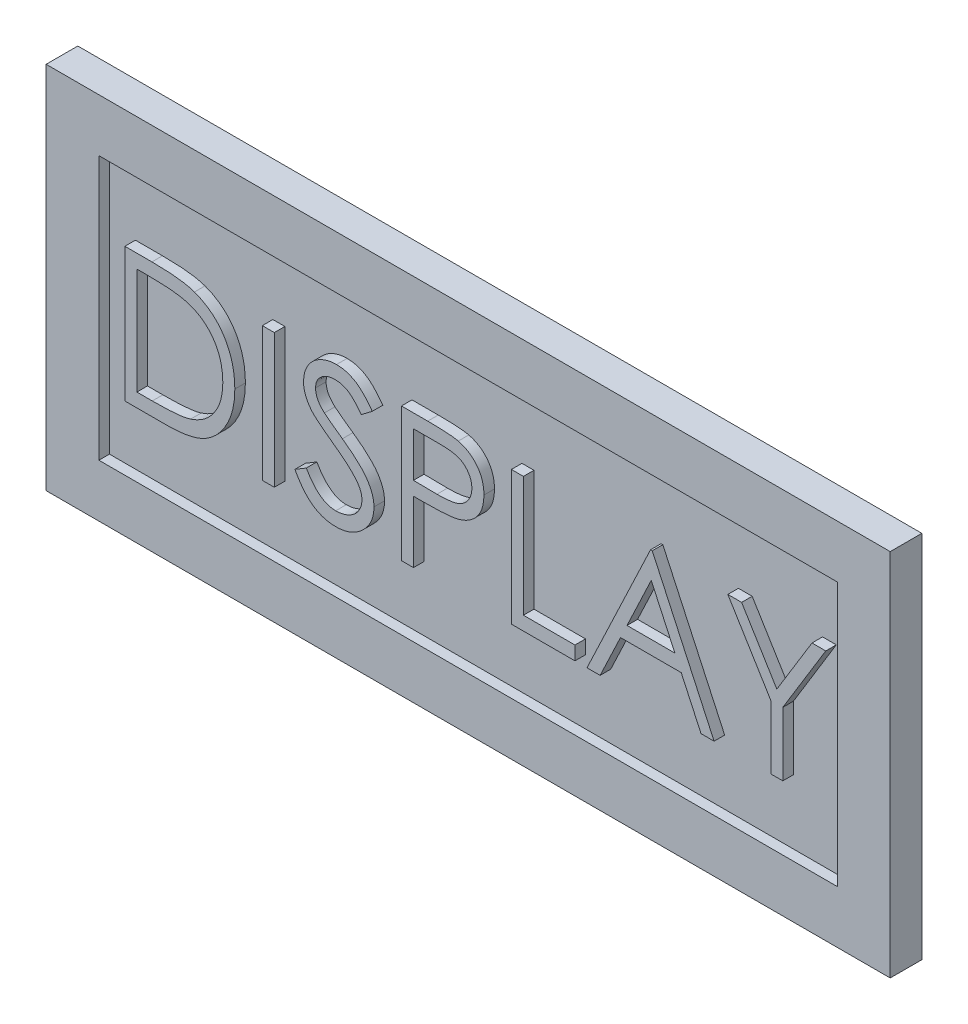
from build123d import *

# Parameters (mm, degrees)
SKETCH_1_W          = 80
SKETCH_1_H          = 35
EXTRUDE_1_DEPTH     = 3
SKETCH_1_4_W        = 70
SKETCH_1_4_H        = 25
CUT_EXTRUDE_1_DEPTH = 4
SKETCH_1_5_W        = 70
SKETCH_1_5_H        = 25
EXTRUDE_2_DEPTH     = 2
SKETCH_8_W          = 1.139743589
SKETCH_8_H          = 12.7
EXTRUDE_3_DEPTH     = 1


with BuildPart() as part:
    # 스케치1 → 보스-돌출1 (new body)
    with BuildSketch(Plane.XY):
        with Locations((40, -17.5)):
            Rectangle(SKETCH_1_W, SKETCH_1_H)
    extrude(amount=EXTRUDE_1_DEPTH)

    # 스케치1<4> → 컷-돌출1 (cut, through all)
    with BuildSketch(Plane.XY):
        with Locations((40, -17.5)):
            Rectangle(SKETCH_1_4_W, SKETCH_1_4_H)
    extrude(amount=CUT_EXTRUDE_1_DEPTH, mode=Mode.SUBTRACT)

    # 스케치1<5> → 보스-돌출2 (add)
    with BuildSketch(Plane.XY):
        with Locations((40, -17.5)):
            Rectangle(SKETCH_1_5_W, SKETCH_1_5_H)
    extrude(amount=EXTRUDE_2_DEPTH)

    # 스케치8 → 보스-돌출3 (add)
    with BuildSketch(Plane.XY.offset(2)):
        with BuildLine():
            Line((7.462006088, -23.907402716), (7.462006088, -11.207402716))
            Line((7.462006088, -11.207402716), (10.026429165, -11.207402716))
            add(Edge.make_bspline(
                [(10.026429165, -11.207402716), (10.249473779, -11.209008613), (10.680394813, -11.212111197), (11.303102837, -11.231783102), (11.879261061, -11.266582792), (12.406974578, -11.317272216), (12.887692119, -11.379513224), (13.32006764, -11.457528976), (13.706336844, -11.549651766), (13.943897385, -11.628193828), (14.056236857, -11.665335408)],
                knots=[0, 0, 0, 0, 0.000669134, 0.001292764, 0.001868826, 0.002400433, 0.002882928, 0.003322552, 0.003718071, 0.004072903, 0.004072903, 0.004072903, 0.004072903], degree=3))
            add(Edge.make_bspline(
                [(14.056236857, -11.665335408), (14.203174911, -11.721326826), (14.493718952, -11.832039961), (14.90740194, -12.040887112), (15.296839685, -12.27751751), (15.664120582, -12.542243069), (16.00085501, -12.842559419), (16.320197949, -13.165709415), (16.609085661, -13.52344425), (16.873638621, -13.908344921), (17.112165157, -14.315877224), (17.319498672, -14.745264619), (17.491688877, -15.194326488), (17.634630013, -15.661814025), (17.747284302, -16.148755167), (17.824144454, -16.65571691), (17.874839189, -17.180695683), (17.879933889, -17.536928737), (17.882518909, -17.717679158)],
                knots=[0, 0, 0, 0, 0.000471477, 0.000932263, 0.001387773, 0.001837613, 0.002288266, 0.002739829, 0.003199145, 0.003665599, 0.004139895, 0.004614383, 0.005094398, 0.005581273, 0.006079917, 0.006592294, 0.007118596, 0.007660698, 0.007660698, 0.007660698, 0.007660698], degree=3))
            add(Edge.make_bspline(
                [(17.882518909, -17.717679158), (17.880236655, -17.874655652), (17.875739236, -18.183994229), (17.835355719, -18.639891193), (17.776658786, -19.082263295), (17.685784125, -19.509003978), (17.575466434, -19.923852083), (17.434082228, -20.322386227), (17.272119142, -20.708262335), (17.083252439, -21.07626289), (16.875910842, -21.42490827), (16.653400517, -21.753568043), (16.415958794, -22.05755242), (16.161321497, -22.337781955), (15.892779212, -22.593834196), (15.608573784, -22.827848081), (15.307971857, -23.035244722), (14.992319805, -23.224173944), (14.652409279, -23.388984948), (14.281801994, -23.528430984), (13.878917433, -23.643988702), (13.444744504, -23.740403096), (12.978533028, -23.816883594), (12.479825923, -23.868142218), (11.949389415, -23.902805716), (11.585156081, -23.905840629), (11.397683171, -23.907402716)],
                knots=[0, 0, 0, 0, 0.000470825, 0.00092781, 0.001372149, 0.001808729, 0.0022358, 0.002659019, 0.003076254, 0.003490407, 0.003898792, 0.004292531, 0.004680333, 0.005054942, 0.00542743, 0.00579259, 0.006158158, 0.00652204, 0.006895248, 0.007289784, 0.007708436, 0.008151601, 0.00862338, 0.009124872, 0.009655071, 0.010217403, 0.010217403, 0.010217403, 0.010217403], degree=3))
            Line((11.397683171, -23.907402716), (7.462006088, -23.907402716))
        make_face()
        with BuildLine():
            Line((8.601749678, -22.604838613), (10.059502082, -22.604838613))
            add(Edge.make_bspline(
                [(10.059502082, -22.604838613), (10.268973598, -22.603938378), (10.671864038, -22.602206896), (11.251194486, -22.58701333), (11.780528296, -22.562186871), (12.25994063, -22.527443017), (12.689160804, -22.481474042), (13.069085839, -22.430220824), (13.398470348, -22.366367216), (13.597785733, -22.308488021), (13.689890703, -22.281741658)],
                knots=[0, 0, 0, 0, 0.000628406, 0.001208655, 0.001738433, 0.002218042, 0.002650422, 0.003033235, 0.00336802, 0.003655635, 0.003655635, 0.003655635, 0.003655635], degree=3))
            add(Edge.make_bspline(
                [(13.689890703, -22.281741658), (13.805817617, -22.240914575), (14.034902533, -22.160235564), (14.364671042, -22.013069193), (14.672217888, -21.838745112), (14.962902837, -21.644971146), (15.232602415, -21.424912796), (15.48451278, -21.183355208), (15.718126745, -20.919069024), (15.931030662, -20.632382266), (16.121560794, -20.325079294), (16.286556398, -20.00018124), (16.431160527, -19.661247957), (16.544657134, -19.303074724), (16.633613683, -18.92886357), (16.696622693, -18.538588167), (16.735864693, -18.132321402), (16.740441947, -17.855997979), (16.742775319, -17.715135088)],
                knots=[0, 0, 0, 0, 0.000368636, 0.000728467, 0.00108158, 0.001428031, 0.001775294, 0.002124361, 0.00247402, 0.002832229, 0.003194399, 0.003557355, 0.003924487, 0.004298604, 0.004683036, 0.005077441, 0.005483744, 0.005906251, 0.005906251, 0.005906251, 0.005906251], degree=3))
            add(Edge.make_bspline(
                [(16.742775319, -17.715135088), (16.740912819, -17.566605031), (16.737253922, -17.274816419), (16.691264281, -16.846678753), (16.624057494, -16.434906107), (16.526870976, -16.039470941), (16.403024644, -15.659601777), (16.248466944, -15.297399554), (16.07187664, -14.94903903), (15.861770246, -14.622560617), (15.631662236, -14.313794193), (15.376291074, -14.030929213), (15.099713962, -13.773321324), (14.804947509, -13.536958675), (14.48368432, -13.33135048), (14.143492356, -13.147430237), (13.779380921, -12.991344003), (13.526060567, -12.908326415), (13.397322594, -12.86613669)],
                knots=[0, 0, 0, 0, 0.000445394, 0.00087498, 0.001290296, 0.001696304, 0.002095342, 0.002487525, 0.00287666, 0.003265537, 0.003650709, 0.004030799, 0.004406986, 0.004783646, 0.005162584, 0.005549584, 0.005942765, 0.00634906, 0.00634906, 0.00634906, 0.00634906], degree=3))
            add(Edge.make_bspline(
                [(13.397322594, -12.86613669), (13.290819863, -12.836685652), (13.064365836, -12.774064664), (12.694834066, -12.705755455), (12.27894481, -12.645504845), (11.814851609, -12.594494245), (11.303083486, -12.557891679), (10.743246846, -12.530418623), (10.13509971, -12.511888842), (9.713523087, -12.510623533), (9.494718428, -12.509966818)],
                knots=[0, 0, 0, 0, 0.000331365, 0.000704572, 0.001126244, 0.001592052, 0.002104832, 0.002665226, 0.00327352, 0.00392991, 0.00392991, 0.00392991, 0.00392991], degree=3))
            Line((9.494718428, -12.509966818), (8.601749678, -12.509966818))
            Line((8.601749678, -12.509966818), (8.601749678, -22.604838613))
        make_face(mode=Mode.SUBTRACT)
        with Locations((21.057518909, -17.557402716)):
            Rectangle(SKETCH_8_W, SKETCH_8_H)
        with BuildLine():
            Line((23.581236857, -21.457462812), (24.654834614, -20.813812972))
            add(Edge.make_bspline(
                [(24.654834614, -20.813812972), (24.754686503, -20.980960883), (24.94599887, -21.301209831), (25.265136659, -21.733946149), (25.595818937, -22.101745975), (25.940494518, -22.402469665), (26.29705953, -22.639229911), (26.667841668, -22.806878009), (27.051591438, -22.911438834), (27.31275359, -22.924139148), (27.443135896, -22.930479639)],
                knots=[0, 0, 0, 0, 0.000583841, 0.001118616, 0.00161028, 0.002064766, 0.002487434, 0.002889373, 0.003281209, 0.003671854, 0.003671854, 0.003671854, 0.003671854], degree=3))
            add(Edge.make_bspline(
                [(27.443135896, -22.930479639), (27.554485361, -22.927378399), (27.775235938, -22.921230183), (28.100218933, -22.862154129), (28.415838616, -22.771395833), (28.715589959, -22.641417025), (28.995336903, -22.484160233), (29.240652626, -22.294218389), (29.452728522, -22.081561586), (29.626207309, -21.844315953), (29.759303437, -21.589165157), (29.861600371, -21.327269562), (29.918369639, -21.054515043), (29.926921287, -20.870871363), (29.931236857, -20.778195985)],
                knots=[0, 0, 0, 0, 0.000333749, 0.000661658, 0.000987706, 0.001317082, 0.001639577, 0.001947946, 0.002244774, 0.002537873, 0.002825803, 0.003105997, 0.003378925, 0.003656975, 0.003656975, 0.003656975, 0.003656975], degree=3))
            add(Edge.make_bspline(
                [(29.931236857, -20.778195985), (29.925887216, -20.67245633), (29.915012176, -20.457503064), (29.823095091, -20.140367181), (29.678499252, -19.826522712), (29.545103374, -19.632389549), (29.475848236, -19.531601434)],
                knots=[0, 0, 0, 0, 0.000316704, 0.000643812, 0.000983014, 0.001349263, 0.001349263, 0.001349263, 0.001349263], degree=3))
            add(Edge.make_bspline(
                [(29.475848236, -19.531601434), (29.418986293, -19.458860102), (29.299611756, -19.306148776), (29.094388782, -19.078836065), (28.853574596, -18.844363516), (28.585410268, -18.593777795), (28.280127346, -18.338733504), (27.947287508, -18.06706861), (27.578392934, -17.789114316), (27.319677617, -17.602705292), (27.186184774, -17.506521306)],
                knots=[0, 0, 0, 0, 0.00027693, 0.00058138, 0.000917785, 0.001285048, 0.001682135, 0.002110847, 0.002573875, 0.003067483, 0.003067483, 0.003067483, 0.003067483], degree=3))
            add(Edge.make_bspline(
                [(27.186184774, -17.506521306), (27.052566274, -17.411349002), (26.797097876, -17.229386805), (26.439833877, -16.959332974), (26.120358254, -16.712430933), (25.840090965, -16.486356375), (25.599155285, -16.281078638), (25.395652623, -16.098568973), (25.234767001, -15.933891481), (25.145302466, -15.827061469), (25.105135094, -15.779097427)],
                knots=[0, 0, 0, 0, 0.000492118, 0.000940893, 0.001343419, 0.001703394, 0.002021005, 0.002292935, 0.002523226, 0.002710868, 0.002710868, 0.002710868, 0.002710868], degree=3))
            add(Edge.make_bspline(
                [(25.105135094, -15.779097427), (25.048991859, -15.704345094), (24.938578651, -15.557334597), (24.792833432, -15.327555828), (24.668957041, -15.092339979), (24.571848007, -14.851054985), (24.490073727, -14.607088243), (24.435072093, -14.35725658), (24.400631881, -14.102681021), (24.397104959, -13.931363462), (24.395339421, -13.845603838)],
                knots=[0, 0, 0, 0, 0.000280379, 0.000551403, 0.000815399, 0.001076659, 0.001330888, 0.001586412, 0.00184296, 0.002100112, 0.002100112, 0.002100112, 0.002100112], degree=3))
            add(Edge.make_bspline(
                [(24.395339421, -13.845603838), (24.400075465, -13.711238656), (24.409446324, -13.445380253), (24.488696201, -13.05701124), (24.613783558, -12.686220526), (24.789025008, -12.336679029), (25.01493026, -12.017488184), (25.276354224, -11.724976389), (25.587727331, -11.479073247), (25.92936685, -11.264218064), (26.303314257, -11.096048564), (26.695166964, -10.96919015), (27.105547768, -10.897310844), (27.383507714, -10.886995668), (27.524546152, -10.88176169)],
                knots=[0, 0, 0, 0, 0.000402767, 0.000796926, 0.001183901, 0.001574148, 0.001965141, 0.002354126, 0.002746681, 0.003151188, 0.003562179, 0.00397332, 0.004384052, 0.004807133, 0.004807133, 0.004807133, 0.004807133], degree=3))
            add(Edge.make_bspline(
                [(27.524546152, -10.88176169), (27.674203316, -10.88692352), (27.97182365, -10.897188753), (28.409607946, -10.986442652), (28.831105403, -11.134127947), (29.170170964, -11.301726792), (29.435538412, -11.469117929), (29.637913757, -11.621589863), (29.842991364, -11.797122399), (30.052425449, -11.996183092), (30.26266727, -12.220598446), (30.476838082, -12.468831518), (30.695438715, -12.739365306), (30.836067122, -12.932494209), (30.908159934, -13.031501274)],
                knots=[0, 0, 0, 0, 0.00044863, 0.000892182, 0.001333892, 0.001785577, 0.002023431, 0.002274276, 0.002544978, 0.002832897, 0.003140645, 0.00346709, 0.003816333, 0.004183702, 0.004183702, 0.004183702, 0.004183702], degree=3))
            Line((30.908159934, -13.031501274), (29.877811377, -13.812530921))
            add(Edge.make_bspline(
                [(29.877811377, -13.812530921), (29.815596136, -13.73238053), (29.695784129, -13.578029617), (29.513885705, -13.361870843), (29.342440611, -13.16441676), (29.17352916, -12.992911867), (29.016072269, -12.837964126), (28.863247573, -12.705304437), (28.717254356, -12.593632991), (28.533224423, -12.474457788), (28.302020131, -12.356324189), (28.011790528, -12.256360391), (27.708491758, -12.196289167), (27.501918524, -12.188346632), (27.397342627, -12.184325793)],
                knots=[0, 0, 0, 0, 0.000304354, 0.000586115, 0.000847462, 0.001088545, 0.001308044, 0.001510038, 0.001695249, 0.001858961, 0.002167298, 0.002471418, 0.002777268, 0.00309085, 0.00309085, 0.00309085, 0.00309085], degree=3))
            add(Edge.make_bspline(
                [(27.397342627, -12.184325793), (27.266146102, -12.188722533), (27.013145965, -12.197201231), (26.653952822, -12.289802321), (26.330669151, -12.435605071), (26.052892701, -12.639947991), (25.821618527, -12.882049879), (25.654321577, -13.160647439), (25.553628122, -13.468286443), (25.541340765, -13.682886167), (25.535083011, -13.792178357)],
                knots=[0, 0, 0, 0, 0.000392785, 0.000757449, 0.001104647, 0.001450678, 0.001785453, 0.002102647, 0.002418029, 0.002745345, 0.002745345, 0.002745345, 0.002745345], degree=3))
            add(Edge.make_bspline(
                [(25.535083011, -13.792178357), (25.536509499, -13.860219436), (25.539364808, -13.996412855), (25.579187645, -14.197622301), (25.630348068, -14.398323447), (25.711419903, -14.597613961), (25.82334429, -14.798979207), (25.970320214, -15.005886655), (26.155425661, -15.220159998), (26.297219391, -15.359523897), (26.37208221, -15.433103838)],
                knots=[0, 0, 0, 0, 0.00020378, 0.000407893, 0.000613397, 0.00082457, 0.001051163, 0.001303142, 0.001584604, 0.001899422, 0.001899422, 0.001899422, 0.001899422], degree=3))
            add(Edge.make_bspline(
                [(26.37208221, -15.433103838), (26.399882047, -15.457912474), (26.465928096, -15.516852116), (26.58667217, -15.613344106), (26.746121752, -15.732371308), (26.940113167, -15.879645285), (27.172223309, -16.050483733), (27.442477698, -16.242702269), (27.747863831, -16.462540934), (27.964569069, -16.616238296), (28.079153524, -16.697506883)],
                knots=[0, 0, 0, 0, 0.000111766, 0.000265529, 0.000463461, 0.000708709, 0.000996201, 0.001328024, 0.001703617, 0.002125051, 0.002125051, 0.002125051, 0.002125051], degree=3))
            add(Edge.make_bspline(
                [(28.079153524, -16.697506883), (28.216988124, -16.79780553), (28.483885723, -16.99201996), (28.863643227, -17.283813999), (29.207972188, -17.569193045), (29.518081526, -17.846334648), (29.79703488, -18.113136585), (30.041737466, -18.372808697), (30.254682649, -18.623490632), (30.483932956, -18.944882549), (30.718185616, -19.339602484), (30.919359085, -19.823212092), (31.046207946, -20.308701598), (31.062796016, -20.635007547), (31.070980447, -20.796004479)],
                knots=[0, 0, 0, 0, 0.000511383, 0.000990223, 0.001436481, 0.001852691, 0.002237729, 0.002594081, 0.002922749, 0.00322352, 0.00377766, 0.004295477, 0.004790951, 0.0052735, 0.0052735, 0.0052735, 0.0052735], degree=3))
            add(Edge.make_bspline(
                [(31.070980447, -20.796004479), (31.068595974, -20.909863118), (31.063873334, -21.135369338), (31.00958659, -21.466494903), (30.930049519, -21.788098344), (30.810171556, -22.096204381), (30.663856096, -22.396449663), (30.478195711, -22.68095833), (30.26299354, -22.956027262), (30.016128165, -23.214321645), (29.745995891, -23.451434984), (29.460486484, -23.662360436), (29.159132637, -23.838231209), (28.843569145, -23.981744265), (28.513723523, -24.093988743), (28.169706708, -24.175315439), (27.810951624, -24.225229019), (27.567109877, -24.230409753), (27.443135896, -24.233043742)],
                knots=[0, 0, 0, 0, 0.000341247, 0.000675867, 0.001004131, 0.001333458, 0.001665681, 0.002004415, 0.002350493, 0.00271219, 0.00307453, 0.00342767, 0.003775427, 0.004119254, 0.004466004, 0.00481897, 0.005178405, 0.005550153, 0.005550153, 0.005550153, 0.005550153], degree=3))
            add(Edge.make_bspline(
                [(27.443135896, -24.233043742), (27.347213366, -24.231188883), (27.15657635, -24.227502525), (26.874601945, -24.194913307), (26.598324007, -24.148804674), (26.331209326, -24.07560162), (26.069816433, -23.986785161), (25.815282182, -23.877426068), (25.567483215, -23.746372223), (25.325030843, -23.596530276), (25.088541695, -23.422149318), (24.860233911, -23.219045488), (24.632616581, -22.99282037), (24.412408029, -22.737330611), (24.195154048, -22.456703853), (23.985138105, -22.148314531), (23.778013015, -21.813842418), (23.648054032, -21.578474822), (23.581236857, -21.457462812)],
                knots=[0, 0, 0, 0, 0.00028766, 0.000571697, 0.000850676, 0.001127139, 0.001401486, 0.001678416, 0.001957221, 0.002241725, 0.002532773, 0.002837436, 0.003157645, 0.003494857, 0.003848519, 0.004221814, 0.00461365, 0.005028294, 0.005028294, 0.005028294, 0.005028294], degree=3))
        make_face()
        with BuildLine():
            Line((33.676108652, -11.207402716), (36.166753684, -11.207402716))
            add(Edge.make_bspline(
                [(36.166753684, -11.207402716), (36.338061829, -11.207591025), (36.666295843, -11.207951834), (37.136976188, -11.218891055), (37.564457215, -11.233502194), (37.947817168, -11.253756493), (38.288235581, -11.277692691), (38.584172068, -11.311264377), (38.837952744, -11.34631745), (38.990013289, -11.381955125), (39.059361857, -11.398208004)],
                knots=[0, 0, 0, 0, 0.000513909, 0.000984672, 0.001412348, 0.001797041, 0.002136358, 0.002435846, 0.002690583, 0.002904164, 0.002904164, 0.002904164, 0.002904164], degree=3))
            add(Edge.make_bspline(
                [(39.059361857, -11.398208004), (39.147149823, -11.422236222), (39.32065714, -11.469726463), (39.570669496, -11.564844831), (39.808536307, -11.677628688), (40.035073676, -11.806166984), (40.247497806, -11.955974603), (40.448978012, -12.120978873), (40.637736226, -12.304989421), (40.812710991, -12.505942392), (40.973401543, -12.720464296), (41.11175782, -12.95175753), (41.227608044, -13.195928831), (41.3269702, -13.452808361), (41.398483735, -13.724553249), (41.452356771, -14.00927532), (41.486551077, -14.306944053), (41.489826087, -14.510361286), (41.491493268, -14.613913133)],
                knots=[0, 0, 0, 0, 0.000272928, 0.000539425, 0.000801167, 0.00106213, 0.001319735, 0.001580002, 0.001842671, 0.002109519, 0.002378686, 0.002645705, 0.002916526, 0.003188682, 0.003470718, 0.003758119, 0.004057607, 0.004368151, 0.004368151, 0.004368151, 0.004368151], degree=3))
            add(Edge.make_bspline(
                [(41.491493268, -14.613913133), (41.489964098, -14.718335351), (41.486972174, -14.922644475), (41.451062796, -15.22154002), (41.402693243, -15.507175322), (41.328318225, -15.778917042), (41.230906783, -16.035151409), (41.116635619, -16.279794165), (40.978809666, -16.50868326), (40.820441284, -16.722649658), (40.644268356, -16.921894197), (40.451036266, -17.104973023), (40.241525119, -17.27081448), (40.016400753, -17.419790355), (39.773468445, -17.548445998), (39.51641263, -17.663679647), (39.242998988, -17.760457496), (39.053796151, -17.811366576), (38.957599037, -17.837250472)],
                knots=[0, 0, 0, 0, 0.000313086, 0.000612574, 0.000902017, 0.001181599, 0.001456135, 0.001723565, 0.001990583, 0.002256192, 0.00252113, 0.002787469, 0.003053674, 0.003321805, 0.003596116, 0.003877417, 0.00416629, 0.004465075, 0.004465075, 0.004465075, 0.004465075], degree=3))
            add(Edge.make_bspline(
                [(38.957599037, -17.837250472), (38.878034139, -17.854170432), (38.70366304, -17.891251508), (38.416488019, -17.932647909), (38.082131905, -17.967981488), (37.70105106, -17.994474188), (37.273587548, -18.017154096), (36.799510129, -18.03518118), (36.277888192, -18.045086649), (35.91404682, -18.045597526), (35.724085415, -18.045864254)],
                knots=[0, 0, 0, 0, 0.000243979, 0.000534694, 0.000869865, 0.0012525, 0.001680517, 0.002154049, 0.002675683, 0.00324556, 0.00324556, 0.00324556, 0.00324556], degree=3))
            Line((35.724085415, -18.045864254), (34.815852242, -18.045864254))
            Line((34.815852242, -18.045864254), (34.815852242, -23.907402716))
            Line((34.815852242, -23.907402716), (33.676108652, -23.907402716))
            Line((33.676108652, -23.907402716), (33.676108652, -11.207402716))
        make_face()
        with BuildLine():
            Line((34.815852242, -12.509966818), (34.815852242, -16.743300152))
            Line((34.815852242, -16.743300152), (37.03936987, -16.771284927))
            add(Edge.make_bspline(
                [(37.03936987, -16.771284927), (37.147936458, -16.771341038), (37.357522018, -16.771449359), (37.660276314, -16.756988691), (37.941161442, -16.740295329), (38.199314615, -16.71585355), (38.434852206, -16.681304987), (38.648166954, -16.64642811), (38.837604809, -16.595971508), (39.059307627, -16.528033514), (39.306352916, -16.412163738), (39.575112306, -16.243979851), (39.802879863, -16.029601281), (39.999977682, -15.78856315), (40.156390439, -15.520414881), (40.270893612, -15.233507596), (40.338171525, -14.930783685), (40.347192857, -14.723635295), (40.351749678, -14.619001274)],
                knots=[0, 0, 0, 0, 0.000325651, 0.000628662, 0.000909076, 0.001169816, 0.001406195, 0.001623278, 0.001817645, 0.001993849, 0.002318305, 0.00263304, 0.002940915, 0.003252021, 0.003564434, 0.003868203, 0.004175604, 0.004489361, 0.004489361, 0.004489361, 0.004489361], degree=3))
            add(Edge.make_bspline(
                [(40.351749678, -14.619001274), (40.347168075, -14.516898668), (40.338060415, -14.313931324), (40.270366283, -14.016465535), (40.156613058, -13.732581694), (39.998927701, -13.467793641), (39.807552744, -13.227622838), (39.585123699, -13.018990406), (39.332164151, -12.851271656), (39.096857712, -12.743019462), (38.887847694, -12.676924034), (38.706303154, -12.63067847), (38.501322707, -12.593755556), (38.272839621, -12.563857932), (38.022624824, -12.538263944), (37.748528653, -12.520897684), (37.451589433, -12.5107324), (37.245448219, -12.510228191), (37.13858862, -12.509966818)],
                knots=[0, 0, 0, 0, 0.000306146, 0.00060858, 0.000909985, 0.001220206, 0.001529716, 0.001828533, 0.002131234, 0.002436321, 0.002602057, 0.002788401, 0.002997974, 0.003226445, 0.00347959, 0.003752387, 0.004050218, 0.004370781, 0.004370781, 0.004370781, 0.004370781], degree=3))
            Line((37.13858862, -12.509966818), (34.815852242, -12.509966818))
        make_face(mode=Mode.SUBTRACT)
        Polygon((44.096621473, -11.207402716), (45.236365062, -11.207402716), (45.236365062, -22.604838613), (50.120980447, -22.604838613), (50.120980447, -23.907402716), (44.096621473, -23.907402716), align=None)
        Polygon((57.447903524, -11.207402716), (63.309441986, -23.907402716), (62.070479646, -23.907402716), (60.192955607, -19.836889895), (54.435724037, -19.836889895), (52.504774518, -23.907402716), (51.260724037, -23.907402716), (57.285083011, -11.207402716), align=None)
        Polygon((57.353772915, -13.682783325), (55.053933171, -18.534325793), (59.592554966, -18.534325793), align=None, mode=Mode.SUBTRACT)
        Polygon((64.612006088, -11.207402716), (65.917114261, -11.207402716), (69.254934774, -16.664433966), (72.587667146, -11.207402716), (73.892775319, -11.207402716), (69.822262498, -17.870323389), (69.822262498, -23.907402716), (68.682518909, -23.907402716), (68.682518909, -17.870323389), align=None)
    extrude(amount=EXTRUDE_3_DEPTH)


solid = part.part
